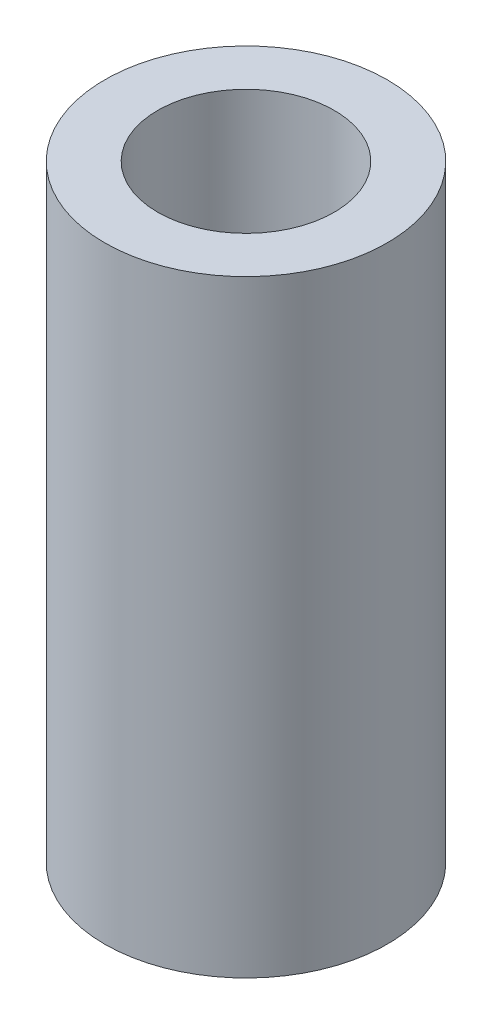
from build123d import *

# Parameters (mm, degrees)
SKETCH1_R           = 4
SKETCH1_R_2         = 2.5
BOSS_EXTRUDE1_DEPTH = 17.2


with BuildPart() as part:
    # Sketch1 → Boss-Extrude1 (new body)
    with BuildSketch(Plane(origin=(0, 0, 0), x_dir=(1, 0, 0), z_dir=(0, 1, 0))):
        Circle(SKETCH1_R)
        Circle(SKETCH1_R_2, mode=Mode.SUBTRACT)
    extrude(amount=BOSS_EXTRUDE1_DEPTH)


solid = part.part
